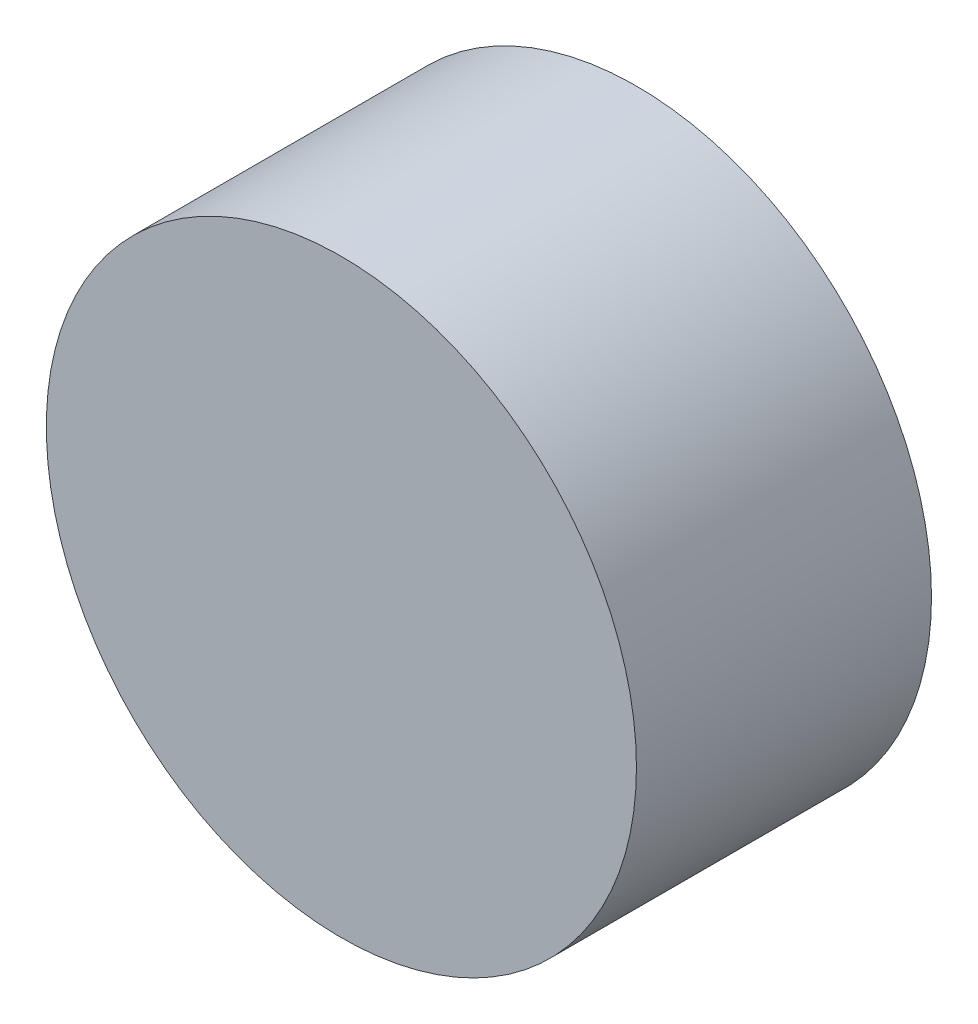
from build123d import *

# Parameters (mm, degrees)
SKETCH1_R           = 20
BOSS_EXTRUDE1_DEPTH = 20


with BuildPart() as part:
    # Sketch1 → Boss-Extrude1 (new body)
    with BuildSketch(Plane.XY):
        Circle(SKETCH1_R)
    extrude(amount=BOSS_EXTRUDE1_DEPTH)


solid = part.part
